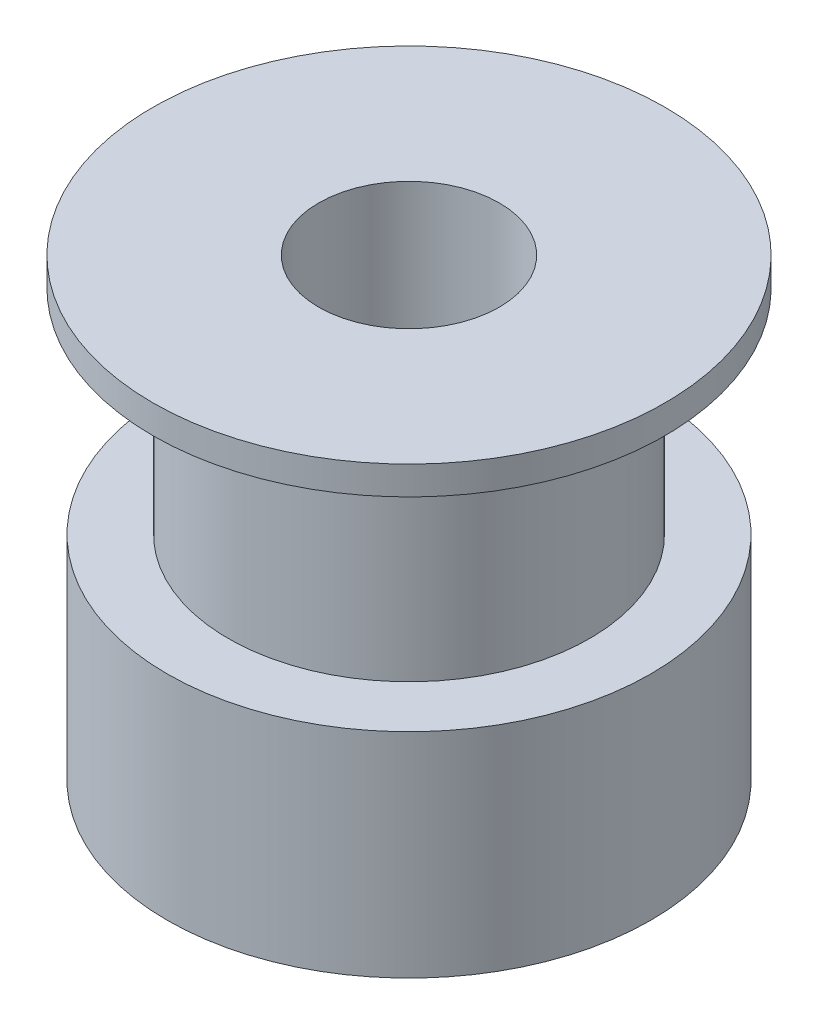
from build123d import *


with BuildPart() as part:
    # Sketch1 → Profile (revolve)
    with BuildSketch(Plane(origin=(0, 0, 0), x_dir=(0, 0, -1), z_dir=(1, 0, 0))):
        Polygon((3.175, -8), (3.175, 8), (9, 8), (9, 7), (6.35, 7), (6.35, -0.5), (8.5, -0.5), (8.5, -8), align=None)
    revolve(axis=Axis((0, -99.30835098, 0), (0, 1, 0)))


solid = part.part
